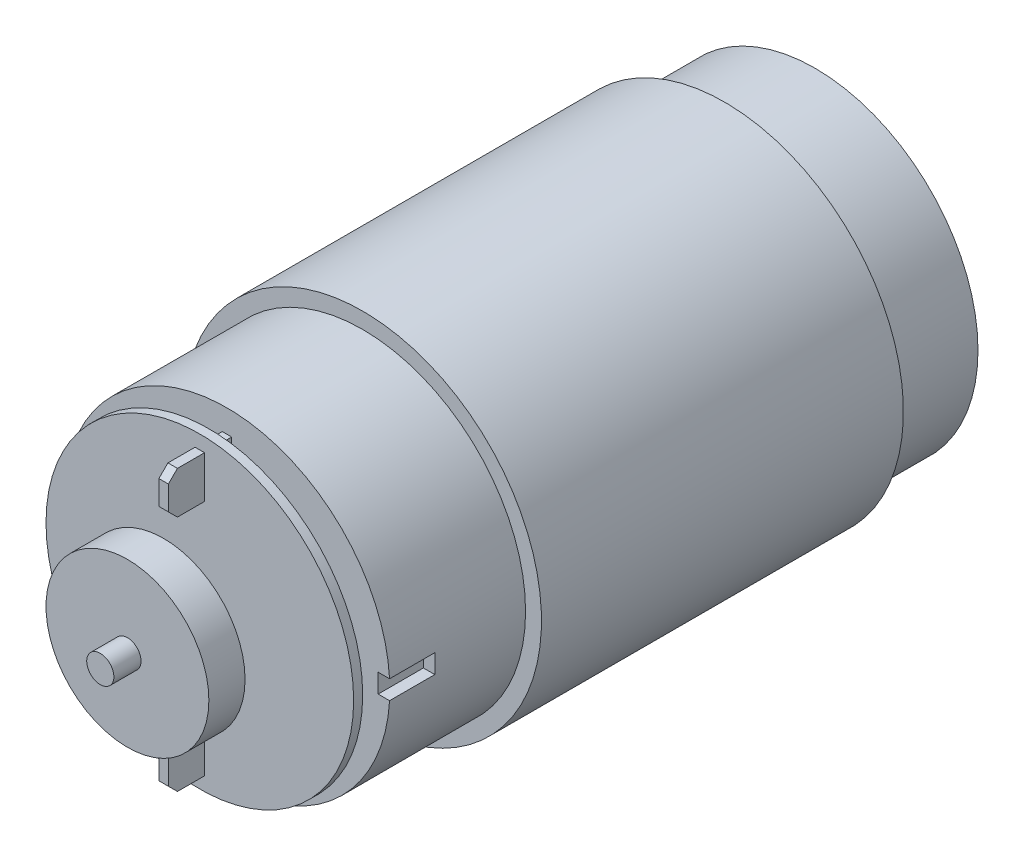
from build123d import *

# Parameters (mm, degrees)
SKETCH1_R           = 18
BOSS_EXTRUDE1_DEPTH = 65
BOSS_EXTRUDE2_START = -10
SKETCH2_R           = 19.758093793
SKETCH2_R_2         = 18
BOSS_EXTRUDE2_DEPTH = 40
SKETCH3_R           = 1.5
BOSS_EXTRUDE3_DEPTH = 14
SKETCH4_R           = 9
BOSS_EXTRUDE4_DEPTH = 2
SKETCH5_R           = 17
BOSS_EXTRUDE5_DEPTH = 1
BOSS_EXTRUDE6_START = -3
SKETCH6_R           = 9
BOSS_EXTRUDE6_DEPTH = 4
SKETCH7_W           = 4.467838664
SKETCH7_H           = 2.096744874
SKETCH7_W_2         = 4.5697238
CUT_EXTRUDE1_DEPTH  = 5
SKETCH8_W           = 1.048372436
SKETCH8_H           = 4.665257343
BOSS_EXTRUDE7_DEPTH = 7
CHAMFER1_SIZE       = 1


with BuildPart() as part:
    # Sketch1 → Boss-Extrude1 (new body)
    with BuildSketch(Plane.XY):
        Circle(SKETCH1_R)
    extrude(amount=BOSS_EXTRUDE1_DEPTH)

    # Sketch2 → Boss-Extrude2 (add)
    with BuildSketch(Plane(origin=(0, 0, 0), x_dir=(-1, 0, 0), z_dir=(0, 0, -1)).offset(BOSS_EXTRUDE2_START)):
        Circle(SKETCH2_R)
        Circle(SKETCH2_R_2, mode=Mode.SUBTRACT)
    extrude(amount=-BOSS_EXTRUDE2_DEPTH)

    # Sketch3 → Boss-Extrude3 (add)
    with BuildSketch(Plane.XY.offset(65)):
        Circle(SKETCH3_R)
    extrude(amount=BOSS_EXTRUDE3_DEPTH)

    # Sketch4 → Boss-Extrude4 (add)
    with BuildSketch(Plane.XY.offset(65)):
        Circle(SKETCH4_R)
    extrude(amount=BOSS_EXTRUDE4_DEPTH)

    # Sketch5 → Boss-Extrude5 (add)
    with BuildSketch(Plane.XY.offset(67)):
        Circle(SKETCH5_R)
    extrude(amount=BOSS_EXTRUDE5_DEPTH)

    # Sketch6 → Boss-Extrude6 (add)
    with BuildSketch(Plane.XY.offset(79).offset(BOSS_EXTRUDE6_START)):
        Circle(SKETCH6_R)
    extrude(amount=-BOSS_EXTRUDE6_DEPTH)

    # Sketch7 → Cut-Extrude1 (cut)
    with BuildSketch(Plane.XY.offset(65)):
        with Locations((18.943203886, 0)):
            Rectangle(SKETCH7_W, SKETCH7_H)
        with Locations((-18.892261318, 0)):
            Rectangle(SKETCH7_W_2, SKETCH7_H)
    extrude(amount=-CUT_EXTRUDE1_DEPTH, mode=Mode.SUBTRACT)

    # Sketch8 → Boss-Extrude7 (add)
    with BuildSketch(Plane.XY.offset(65)):
        with Locations((0, 13.130864768)):
            Rectangle(SKETCH8_W, SKETCH8_H)
        with Locations((0, -13.130864768)):
            Rectangle(SKETCH8_W, SKETCH8_H)
    extrude(amount=BOSS_EXTRUDE7_DEPTH)

    # Chamfer1
    chamfer1_edges = [part.edges().sort_by_distance(p)[0] for p in [
        (0, -15.463493439, 72),
        (0, -10.798236096, 72),
        (0, 15.463493439, 72),
        (0, 10.798236096, 72),
    ]]
    chamfer(chamfer1_edges, length=CHAMFER1_SIZE)


solid = part.part
